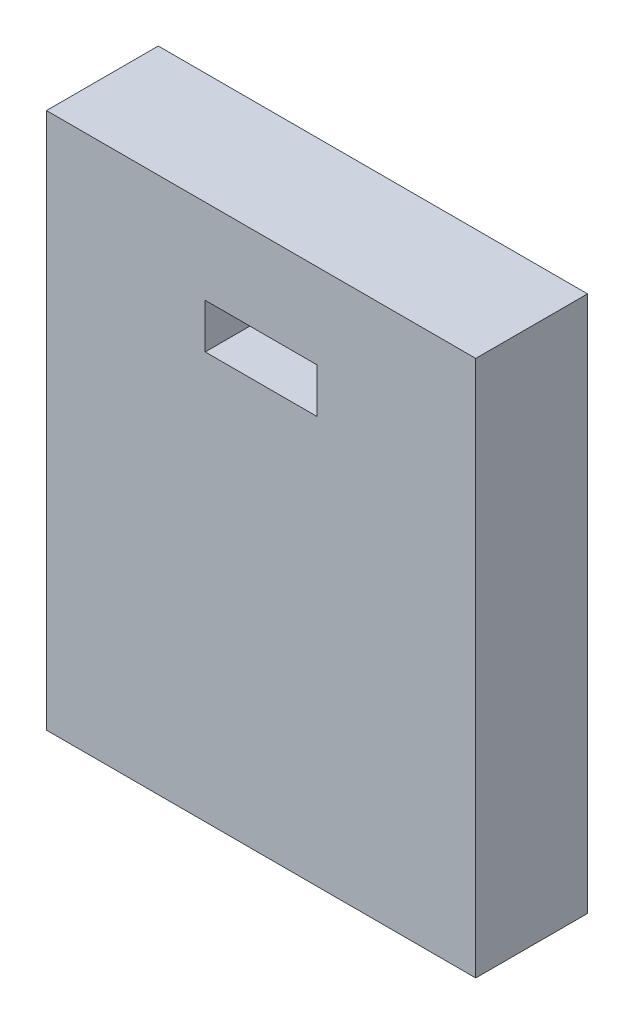
from build123d import *

# Parameters (mm, degrees)
SKETCH1_W           = 12.192
SKETCH1_H           = 15.24
BOSS_EXTRUDE1_DEPTH = 3.175
SKETCH2_W           = 3.175
SKETCH2_H           = 1.27
CUT_EXTRUDE1_DEPTH  = 3.175


with BuildPart() as part:
    # Sketch1 → Boss-Extrude1 (new body)
    with BuildSketch(Plane.XY):
        with Locations((6.096, 7.62)):
            Rectangle(SKETCH1_W, SKETCH1_H)
    extrude(amount=BOSS_EXTRUDE1_DEPTH)

    # Sketch2 → Cut-Extrude1 (cut)
    with BuildSketch(Plane.XY.offset(3.175)):
        with Locations((6.096, 12.192)):
            Rectangle(SKETCH2_W, SKETCH2_H)
    extrude(amount=-CUT_EXTRUDE1_DEPTH, mode=Mode.SUBTRACT)


solid = part.part
